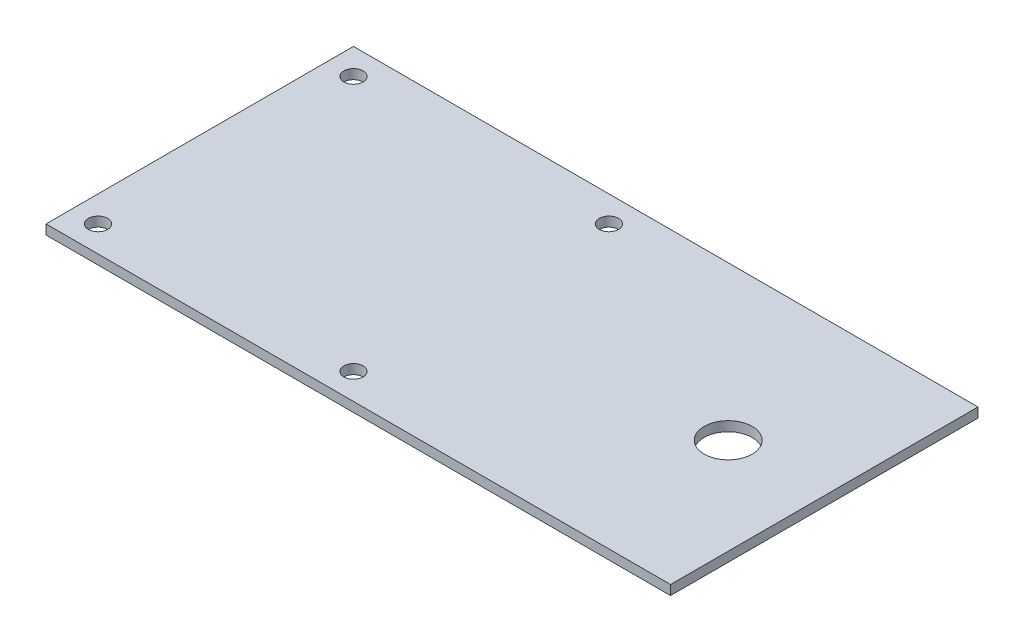
from build123d import *

# Parameters (mm, degrees)
CROQUIS1_W              = 650
CROQUIS1_H              = 320
CROQUIS1_R              = 10
CROQUIS1_R_2            = 25
SALIENTE_EXTRUIR1_DEPTH = 10


with BuildPart() as part:
    # Croquis1 → Saliente-Extruir1 (new body)
    with BuildSketch(Plane(origin=(0, 0, 0), x_dir=(1, 0, 0), z_dir=(0, 1, 0))):
        with Locations((25, 0)):
            Rectangle(CROQUIS1_W, CROQUIS1_H)
        with Locations((-272.936074863, 132.936074863)):
            Circle(CROQUIS1_R, mode=Mode.SUBTRACT)
        with Locations((-7.063925137, 132.936074863)):
            Circle(CROQUIS1_R, mode=Mode.SUBTRACT)
        with Locations((-7.063925137, -132.936074863)):
            Circle(CROQUIS1_R, mode=Mode.SUBTRACT)
        with Locations((-272.936074863, -132.936074863)):
            Circle(CROQUIS1_R, mode=Mode.SUBTRACT)
        with Locations((250, 0)):
            Circle(CROQUIS1_R_2, mode=Mode.SUBTRACT)
    extrude(amount=SALIENTE_EXTRUIR1_DEPTH)


solid = part.part
